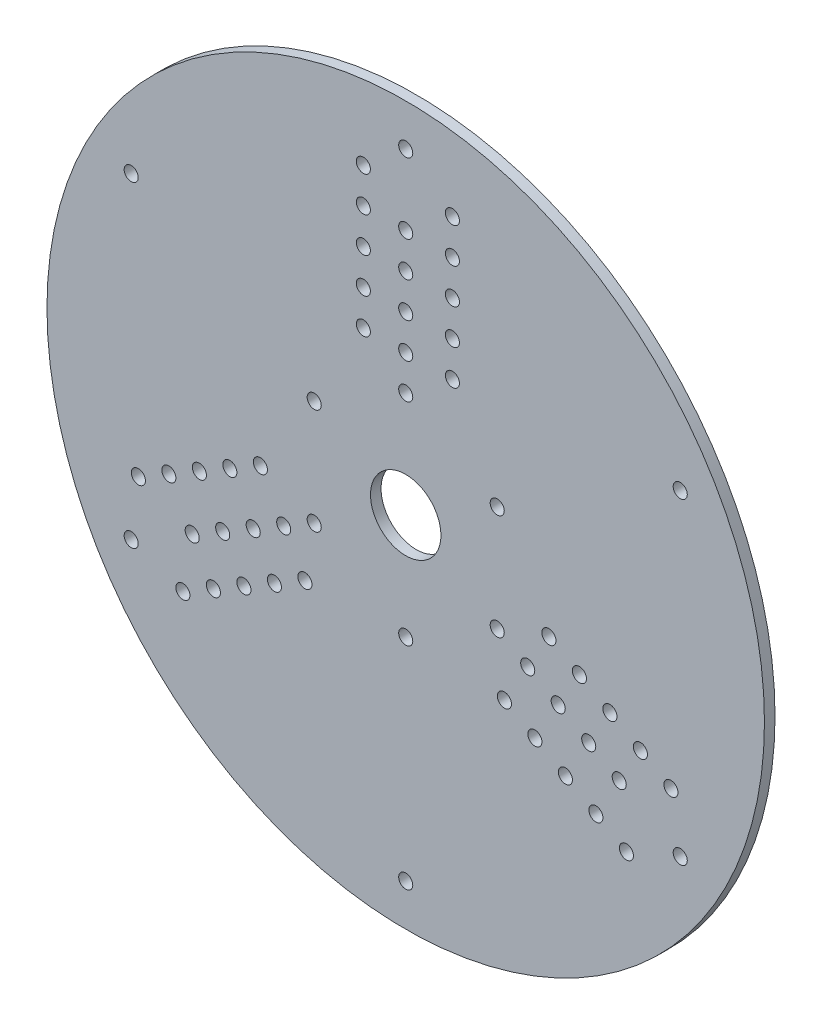
from build123d import *

# Parameters (mm, degrees)
SKETCH1_R           = 101.859163579
SKETCH1_R_2         = 2
SKETCH1_R_3         = 10
BOSS_EXTRUDE1_DEPTH = 3


with BuildPart() as part:
    # Sketch1 → Boss-Extrude1 (new body)
    with BuildSketch(Plane.XY):
        Circle(SKETCH1_R)
        with Locations((0, 30)):
            Circle(SKETCH1_R_2, mode=Mode.SUBTRACT)
        with Locations((-12.031885298, 50)):
            Circle(SKETCH1_R_2, mode=Mode.SUBTRACT)
        with Locations((0, 40)):
            Circle(SKETCH1_R_2, mode=Mode.SUBTRACT)
        with Locations((13.252061667, 50)):
            Circle(SKETCH1_R_2, mode=Mode.SUBTRACT)
        with Locations((-12.031885298, 60)):
            Circle(SKETCH1_R_2, mode=Mode.SUBTRACT)
        with Locations((-12.031885298, 40)):
            Circle(SKETCH1_R_2, mode=Mode.SUBTRACT)
        with Locations((13.252061667, 40)):
            Circle(SKETCH1_R_2, mode=Mode.SUBTRACT)
        with Locations((0, 50)):
            Circle(SKETCH1_R_2, mode=Mode.SUBTRACT)
        with Locations((13.252061667, 60)):
            Circle(SKETCH1_R_2, mode=Mode.SUBTRACT)
        with Locations((-12.031885298, 70)):
            Circle(SKETCH1_R_2, mode=Mode.SUBTRACT)
        with Locations((0, 60)):
            Circle(SKETCH1_R_2, mode=Mode.SUBTRACT)
        with Locations((13.252061667, 70)):
            Circle(SKETCH1_R_2, mode=Mode.SUBTRACT)
        with Locations((-12.031885298, 80)):
            Circle(SKETCH1_R_2, mode=Mode.SUBTRACT)
        with Locations((0, 70)):
            Circle(SKETCH1_R_2, mode=Mode.SUBTRACT)
        with Locations((13.252061667, 80)):
            Circle(SKETCH1_R_2, mode=Mode.SUBTRACT)
        with Locations((25.980762114, -15)):
            Circle(SKETCH1_R_2, mode=Mode.SUBTRACT)
        with Locations((49.317212838, -14.580081677)):
            Circle(SKETCH1_R_2, mode=Mode.SUBTRACT)
        with Locations((34.641016151, -20)):
            Circle(SKETCH1_R_2, mode=Mode.SUBTRACT)
        with Locations((36.675239356, -36.476622056)):
            Circle(SKETCH1_R_2, mode=Mode.SUBTRACT)
        with Locations((57.977466876, -19.580081677)):
            Circle(SKETCH1_R_2, mode=Mode.SUBTRACT)
        with Locations((40.6569588, -9.580081677)):
            Circle(SKETCH1_R_2, mode=Mode.SUBTRACT)
        with Locations((28.014985318, -31.476622056)):
            Circle(SKETCH1_R_2, mode=Mode.SUBTRACT)
        with Locations((43.301270189, -25)):
            Circle(SKETCH1_R_2, mode=Mode.SUBTRACT)
        with Locations((45.335493393, -41.476622056)):
            Circle(SKETCH1_R_2, mode=Mode.SUBTRACT)
        with Locations((66.637720914, -24.580081677)):
            Circle(SKETCH1_R_2, mode=Mode.SUBTRACT)
        with Locations((51.961524227, -30)):
            Circle(SKETCH1_R_2, mode=Mode.SUBTRACT)
        with Locations((53.995747431, -46.476622056)):
            Circle(SKETCH1_R_2, mode=Mode.SUBTRACT)
        with Locations((75.297974952, -29.580081677)):
            Circle(SKETCH1_R_2, mode=Mode.SUBTRACT)
        with Locations((60.621778265, -35)):
            Circle(SKETCH1_R_2, mode=Mode.SUBTRACT)
        with Locations((62.656001469, -51.476622056)):
            Circle(SKETCH1_R_2, mode=Mode.SUBTRACT)
        with Locations((-25.980762114, -15)):
            Circle(SKETCH1_R_2, mode=Mode.SUBTRACT)
        with Locations((-37.28532754, -35.419918323)):
            Circle(SKETCH1_R_2, mode=Mode.SUBTRACT)
        with Locations((-34.641016151, -20)):
            Circle(SKETCH1_R_2, mode=Mode.SUBTRACT)
        with Locations((-49.927301023, -13.523377944)):
            Circle(SKETCH1_R_2, mode=Mode.SUBTRACT)
        with Locations((-45.945581578, -40.419918323)):
            Circle(SKETCH1_R_2, mode=Mode.SUBTRACT)
        with Locations((-28.625073502, -30.419918323)):
            Circle(SKETCH1_R_2, mode=Mode.SUBTRACT)
        with Locations((-41.267046985, -8.523377944)):
            Circle(SKETCH1_R_2, mode=Mode.SUBTRACT)
        with Locations((-43.301270189, -25)):
            Circle(SKETCH1_R_2, mode=Mode.SUBTRACT)
        with Locations((-58.587555061, -18.523377944)):
            Circle(SKETCH1_R_2, mode=Mode.SUBTRACT)
        with Locations((-54.605835616, -45.419918323)):
            Circle(SKETCH1_R_2, mode=Mode.SUBTRACT)
        with Locations((-51.961524227, -30)):
            Circle(SKETCH1_R_2, mode=Mode.SUBTRACT)
        with Locations((-67.247809099, -23.523377944)):
            Circle(SKETCH1_R_2, mode=Mode.SUBTRACT)
        with Locations((-63.266089654, -50.419918323)):
            Circle(SKETCH1_R_2, mode=Mode.SUBTRACT)
        with Locations((-60.621778265, -35)):
            Circle(SKETCH1_R_2, mode=Mode.SUBTRACT)
        with Locations((-75.908063136, -28.523377944)):
            Circle(SKETCH1_R_2, mode=Mode.SUBTRACT)
        with Locations((77.942286341, 45)):
            Circle(SKETCH1_R_2, mode=Mode.SUBTRACT)
        with Locations((77.942286341, -45)):
            Circle(SKETCH1_R_2, mode=Mode.SUBTRACT)
        with Locations((0, -90)):
            Circle(SKETCH1_R_2, mode=Mode.SUBTRACT)
        with Locations((-77.942286341, -45)):
            Circle(SKETCH1_R_2, mode=Mode.SUBTRACT)
        with Locations((-77.942286341, 45)):
            Circle(SKETCH1_R_2, mode=Mode.SUBTRACT)
        with Locations((0, 90)):
            Circle(SKETCH1_R_2, mode=Mode.SUBTRACT)
        Circle(SKETCH1_R_3, mode=Mode.SUBTRACT)
        with Locations((25.980762114, 15)):
            Circle(SKETCH1_R_2, mode=Mode.SUBTRACT)
        with Locations((0, -30)):
            Circle(SKETCH1_R_2, mode=Mode.SUBTRACT)
        with Locations((-25.980762114, 15)):
            Circle(SKETCH1_R_2, mode=Mode.SUBTRACT)
    extrude(amount=BOSS_EXTRUDE1_DEPTH)


solid = part.part
